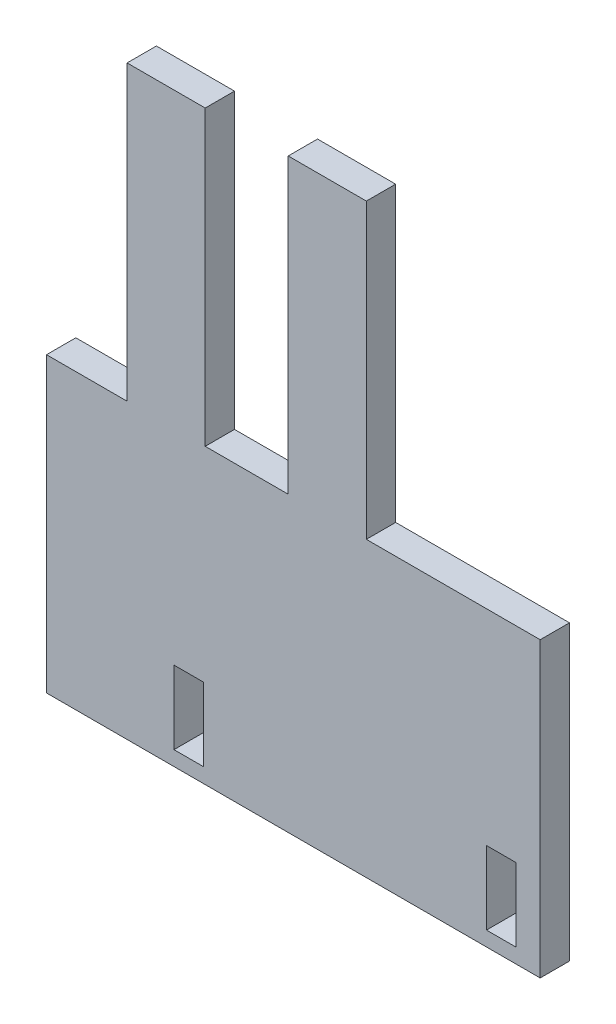
from build123d import *

# Parameters (mm, degrees)
ESQUISSE1_W        = 6
ESQUISSE1_H        = 15
BOSS_EXTRU_1_DEPTH = 6


with BuildPart() as part:
    # Esquisse1 → Boss.-Extru.1 (new body)
    with BuildSketch(Plane.XY):
        Polygon((42.167583758, -72.618715084), (42.167583758, -12.618715084), (6.567583758, -12.618715084), (6.567583758, 47.381284916), (-9.432416242, 47.381284916), (-9.432416242, -12.618715084), (-26.432416242, -12.618715084), (-26.432416242, 47.381284916), (-42.432416242, 47.381284916), (-42.432416242, -12.618715084), (-58.932416242, -12.618715084), (-58.932416242, -72.618715084), align=None)
        with Locations((34.167583758, -62.118715084)):
            Rectangle(ESQUISSE1_W, ESQUISSE1_H, mode=Mode.SUBTRACT)
        with Locations((-29.832416242, -62.118715084)):
            Rectangle(ESQUISSE1_W, ESQUISSE1_H, mode=Mode.SUBTRACT)
    extrude(amount=BOSS_EXTRU_1_DEPTH)


solid = part.part
